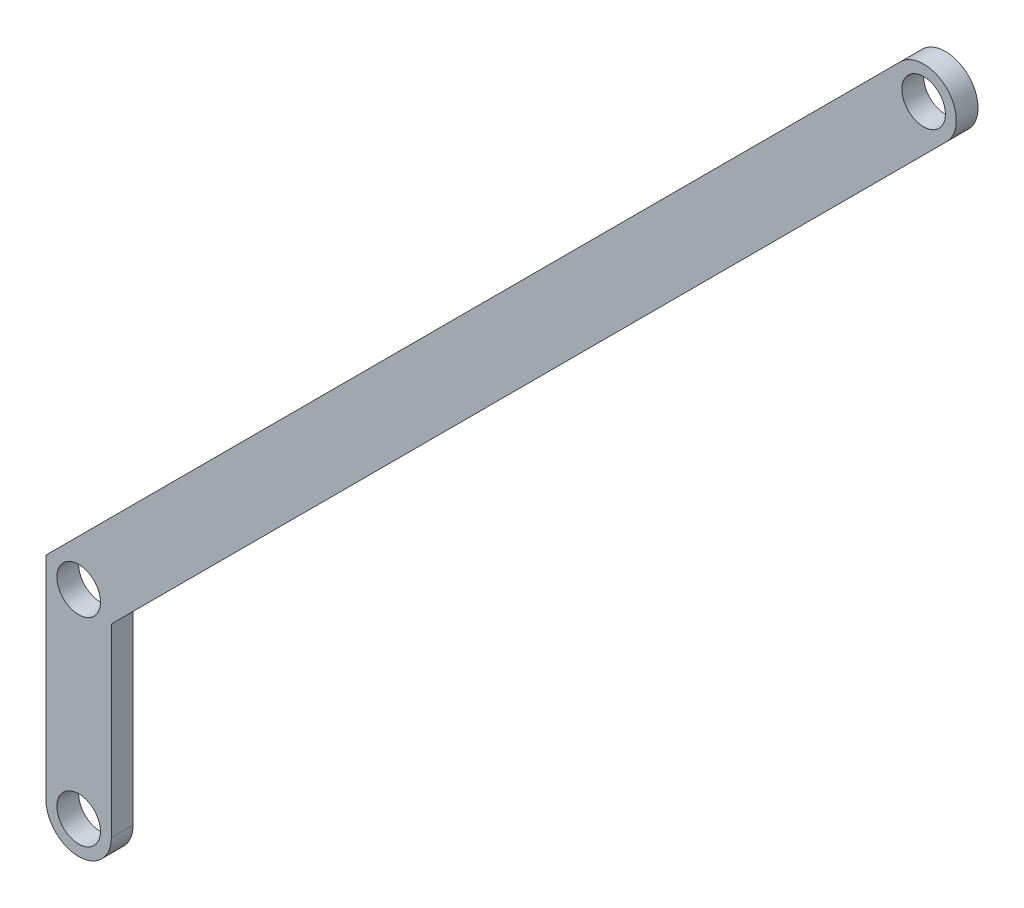
from build123d import *

# Parameters (mm, degrees)
BOSS_EXTRUDE1_DEPTH = 5
SKETCH2_R           = 5
CUT_EXTRUDE1_DEPTH  = 5
SKETCH3_R           = 5
CUT_EXTRUDE2_DEPTH  = 6


with BuildPart() as part:
    # Sketch1 → Boss-Extrude1 (new body)
    with BuildSketch(Plane.XY):
        Polygon((-97.771110706, 14.82204599), (-97.771110706, -41.391157445), (-82.771110706, -41.391157445), (-82.771110706, 8.608842555), (114.36092365, 205.740876911), (103.754321932, 216.347478628), align=None)
    extrude(amount=BOSS_EXTRUDE1_DEPTH)

    # Sketch2 → Cut-Extrude1 (cut)
    with BuildSketch(Plane.XY.offset(5)):
        with Locations((-90.271110706, -33.891157445)):
            Circle(SKETCH2_R)
        with BuildLine():
            ThreePointArc((-90.271110669, -41.391157445), (-95.574411596, -39.194458273), (-97.771110706, -33.891157321))
            Line((-97.771110706, -33.891157321), (-97.771110706, -41.391157445))
            Line((-97.771110706, -41.391157445), (-90.271110669, -41.391157445))
        make_face()
        with BuildLine():
            Line((-82.771110706, -41.391157445), (-82.771110706, -33.891157445))
            ThreePointArc((-82.771110706, -33.891157445), (-84.967809834, -39.194458291), (-90.271110669, -41.391157445))
            Line((-90.271110669, -41.391157445), (-82.771110706, -41.391157445))
        make_face()
        with Locations((103.754321932, 205.740876911)):
            Circle(SKETCH2_R)
        with BuildLine():
            Line((109.057622903, 211.044177658), (103.754321932, 216.347478628))
            Line((103.754321932, 216.347478628), (98.451021073, 211.04417777))
            ThreePointArc((98.451021073, 211.04417777), (103.754322011, 213.240876911), (109.057622903, 211.044177658))
        make_face()
        with BuildLine():
            Line((114.36092365, 205.740876911), (109.057622903, 211.044177658))
            ThreePointArc((109.057622903, 211.044177658), (110.683418456, 208.61100258), (111.254321932, 205.740876911))
            ThreePointArc((111.254321932, 205.740876911), (110.683418433, 202.870751185), (109.057622817, 200.437576078))
            Line((109.057622817, 200.437576078), (114.36092365, 205.740876911))
        make_face()
    extrude(amount=-CUT_EXTRUDE1_DEPTH, mode=Mode.SUBTRACT)

    # Sketch3 → Cut-Extrude2 (cut, through all)
    with BuildSketch(Plane.XY.offset(5)):
        with Locations((-90.271110706, 11.715444272)):
            Circle(SKETCH3_R)
    extrude(amount=-CUT_EXTRUDE2_DEPTH, mode=Mode.SUBTRACT)


solid = part.part
